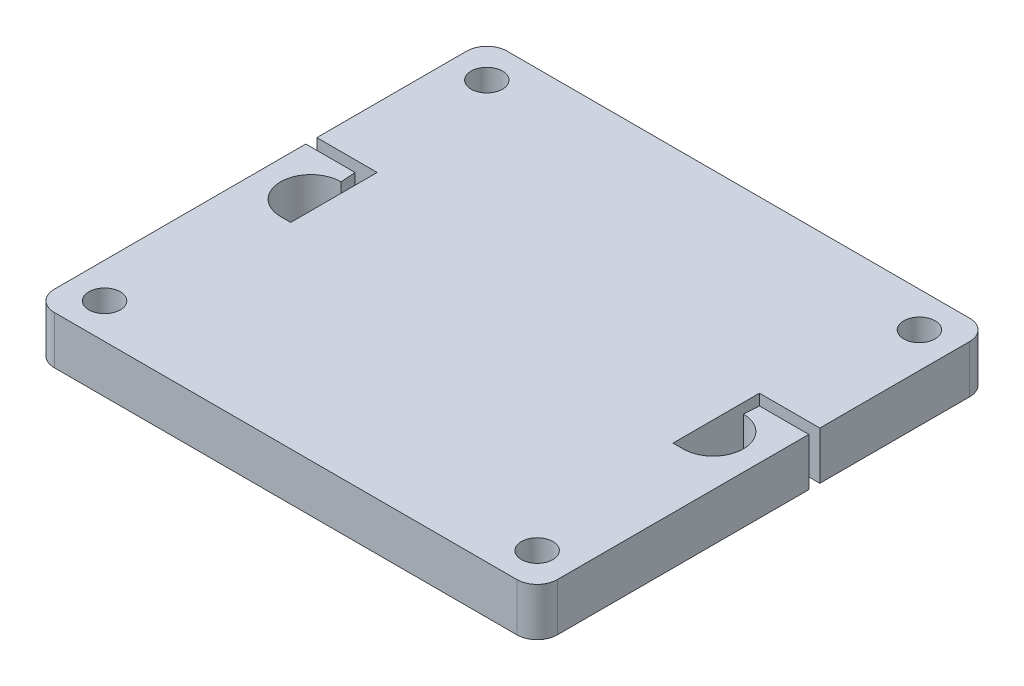
from build123d import *

# Parameters (mm, degrees)
SKETCH1_W           = 50
SKETCH1_H           = 45
SKETCH1_R           = 1.5625
BOSS_EXTRUDE1_DEPTH = 4.7625
FILLET1_R           = 2
CUT_EXTRUDE1_DEPTH  = 5.7625


with BuildPart() as part:
    # Sketch1 → Boss-Extrude1 (new body)
    with BuildSketch(Plane(origin=(0, 0, 0), x_dir=(1, 0, 0), z_dir=(0, 1, 0))):
        Rectangle(SKETCH1_W, SKETCH1_H)
        with Locations((-21.5, 19)):
            Circle(SKETCH1_R, mode=Mode.SUBTRACT)
        with Locations((21.5, 19)):
            Circle(SKETCH1_R, mode=Mode.SUBTRACT)
        with Locations((21.5, -19)):
            Circle(SKETCH1_R, mode=Mode.SUBTRACT)
        with Locations((-21.5, -19)):
            Circle(SKETCH1_R, mode=Mode.SUBTRACT)
    extrude(amount=BOSS_EXTRUDE1_DEPTH)

    # Fillet1
    fillet1_edges = [part.edges().sort_by_distance(p)[0] for p in [
        (-25, 2.38125, -22.5),
        (25, 2.38125, -22.5),
        (25, 2.38125, 22.5),
        (-25, 2.38125, 22.5),
    ]]
    fillet(fillet1_edges, radius=FILLET1_R)

    # Sketch2 → Cut-Extrude1 (cut, through all)
    with BuildSketch(Plane(origin=(0, 4.7625, 0), x_dir=(1, 0, 0), z_dir=(0, 1, 0))):
        with BuildLine():
            Line((-25, 5.6), (-19, 5.6))
            Line((-19, 5.6), (-19, -3))
            Line((-19, -3), (-20, -3))
            ThreePointArc((-20, -3), (-23, 0), (-20, 3))
            Line((-20, 3), (-20.1, 4.5))
            Line((-20.1, 4.5), (-25, 4.5))
            Line((-25, 4.5), (-25, 5.6))
        make_face()
    cut_extrude1 = extrude(amount=-CUT_EXTRUDE1_DEPTH, mode=Mode.SUBTRACT)

    # Mirror1: Cut-Extrude1 across plane
    add(cut_extrude1.mirror(Plane(origin=(0, 0, 0), x_dir=(0, 0, 1), z_dir=(1, 0, 0))), mode=Mode.SUBTRACT)


solid = part.part
